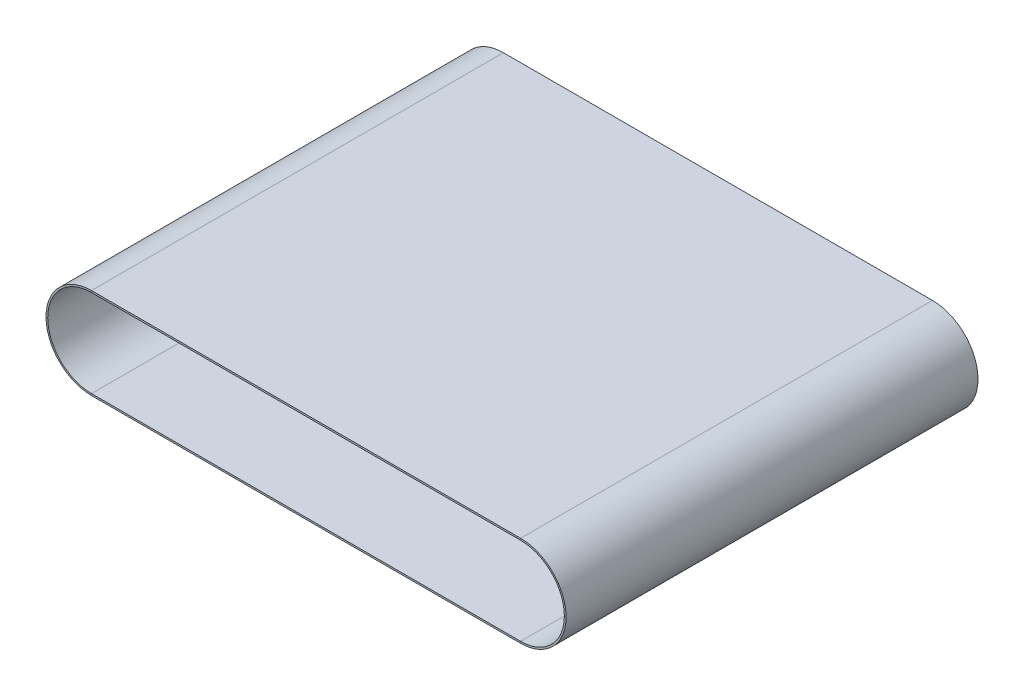
from build123d import *

# Parameters (mm, degrees)
SKETCH2_W = 240
SKETCH2_H = 1


with BuildPart() as part:
    # Sweep1: sweep along a path in Sketch1
    with BuildLine(Plane.XY) as sweep1_path:
        Line((-250, -25.5), (0, -25.5))
        ThreePointArc((0, -25.5), (25.5, 0), (0, 25.5))
        Line((0, 25.5), (-250, 25.5))
        ThreePointArc((-250, 25.5), (-275.5, 0), (-250, -25.5))
    # Sketch2 → Sweep1 (sweep)
    with BuildSketch(Plane(origin=(0, 0, 0), x_dir=(0, 0, -1), z_dir=(1, 0, 0))):
        with Locations((0, 26)):
            Rectangle(SKETCH2_W, SKETCH2_H)
    sweep(path=sweep1_path.line)


solid = part.part
